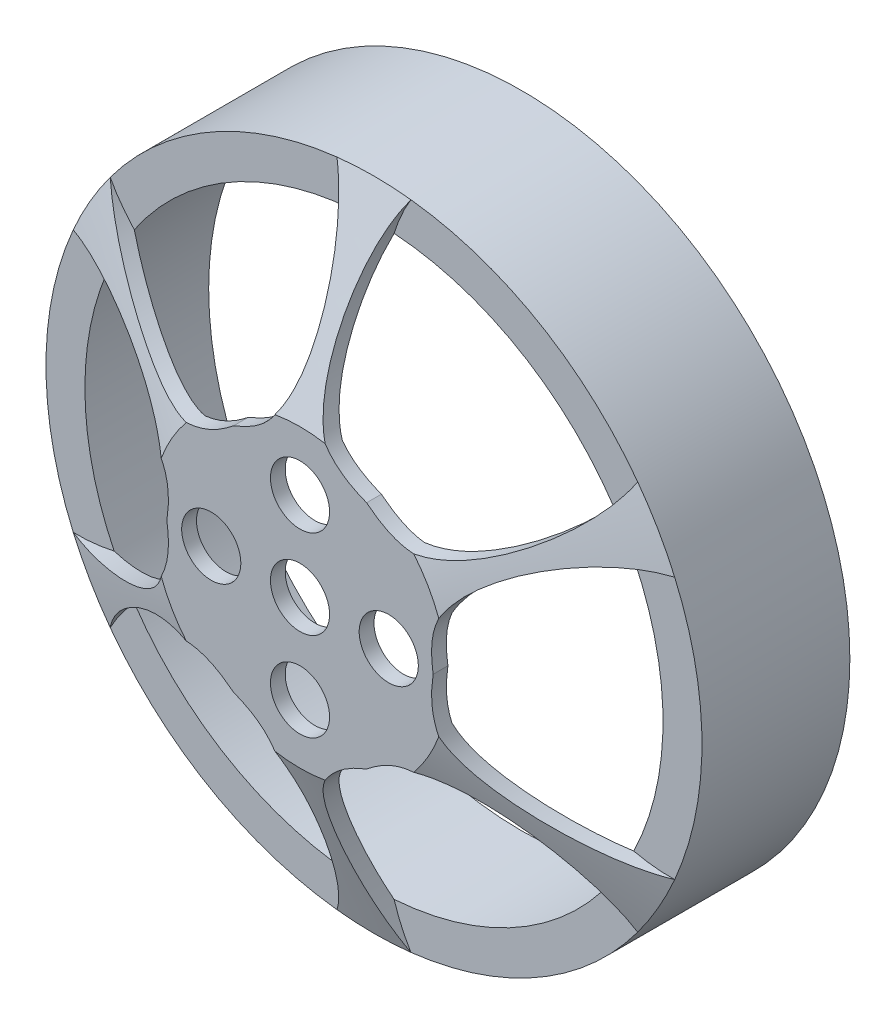
from build123d import *

# Parameters (mm, degrees)
SKETCH1_R           = 22.175
BOSS_EXTRUDE1_DEPTH = 10
SKETCH2_R           = 10
SHELL1_T            = -1
SKETCH3_R           = 2
CUT_EXTRUDE1_DEPTH  = 5


with BuildPart() as part:
    # Sketch1 → Boss-Extrude1 (new body)
    with BuildSketch(Plane.XY):
        Circle(SKETCH1_R)
    extrude(amount=BOSS_EXTRUDE1_DEPTH)

    # Sketch2 → section 0 of loft1
    with BuildSketch(Plane.XY.offset(15), mode=Mode.PRIVATE) as loft1_s0:
        Circle(SKETCH2_R)
    # loft up to a face of the part (loft1)
    loft([loft1_s0.sketch, Face(Wire([part.edges().sort_by_distance((-15.179832074, 16.164879313, 10))[0]]))])

    # Shell1
    shell1_openings = [part.faces().sort_by_distance(p)[0] for p in [
        (0, 0, 0),
    ]]
    offset(amount=SHELL1_T, openings=shell1_openings, kind=Kind.INTERSECTION)

    # Sketch3 → Cut-Extrude1 (cut)
    with BuildSketch(Plane.XY.offset(15)):
        Circle(SKETCH3_R)
        with Locations((0, 6)):
            Circle(SKETCH3_R)
        with Locations((6, 0)):
            Circle(SKETCH3_R)
        with Locations((0, -6)):
            Circle(SKETCH3_R)
        with Locations((-6, 0)):
            Circle(SKETCH3_R)
        with BuildLine():
            ThreePointArc((-20.331678877, 8.851748927), (-22.175, 0), (-20.331678877, -8.851748927))
            add(Edge.make_bspline(
                [(-20.331678877, -8.851748927), (-15.665918568, -9.044722303), (-9.625250911, -5.557141204), (-8.451567627, -3.688890956), (-9, 0)],
                knots=[0, 0, 0, 0, 0, 1, 1, 1, 1, 1], degree=4))
            add(Edge.make_bspline(
                [(-20.331678877, 8.851748927), (-15.665918568, 9.044722303), (-9.625250911, 5.557141204), (-8.451567627, 3.688890956), (-9, 0)],
                knots=[0, 0, 0, 0, 0, 1, 1, 1, 1, 1], degree=4))
        make_face()
        with BuildLine():
            ThreePointArc((-2.5, 22.033624872), (-11.0875, 19.204113329), (-17.831678877, 13.181875945))
            add(Edge.make_bspline(
                [(-17.831678877, 13.181875945), (-15.665918568, 9.044722303), (-9.625250911, 5.557141204), (-7.420457094, 5.474826789), (-4.5, 7.794228634)],
                knots=[0, 0, 0, 0, 0, 1, 1, 1, 1, 1], degree=4))
            add(Edge.make_bspline(
                [(-2.5, 22.033624872), (0, 18.089444605), (0, 11.114282409), (-1.031110534, 9.163717745), (-4.5, 7.794228634)],
                knots=[0, 0, 0, 0, 0, 1, 1, 1, 1, 1], degree=4))
        make_face()
        with BuildLine():
            ThreePointArc((17.831678877, 13.181875945), (11.0875, 19.204113329), (2.5, 22.033624872))
            add(Edge.make_bspline(
                [(2.5, 22.033624872), (0, 18.089444605), (0, 11.114282409), (1.031110534, 9.163717745), (4.5, 7.794228634)],
                knots=[0, 0, 0, 0, 0, 1, 1, 1, 1, 1], degree=4))
            add(Edge.make_bspline(
                [(17.831678877, 13.181875945), (15.665918568, 9.044722303), (9.625250911, 5.557141204), (7.420457094, 5.474826789), (4.5, 7.794228634)],
                knots=[0, 0, 0, 0, 0, 1, 1, 1, 1, 1], degree=4))
        make_face()
        with BuildLine():
            ThreePointArc((20.331678877, -8.851748927), (22.175, 0), (20.331678877, 8.851748927))
            add(Edge.make_bspline(
                [(20.331678877, 8.851748927), (15.665918568, 9.044722303), (9.625250911, 5.557141204), (8.451567627, 3.688890956), (9, 0)],
                knots=[0, 0, 0, 0, 0, 1, 1, 1, 1, 1], degree=4))
            add(Edge.make_bspline(
                [(20.331678877, -8.851748927), (15.665918568, -9.044722303), (9.625250911, -5.557141204), (8.451567627, -3.688890956), (9, 0)],
                knots=[0, 0, 0, 0, 0, 1, 1, 1, 1, 1], degree=4))
        make_face()
        with BuildLine():
            ThreePointArc((-17.831678877, -13.181875945), (-11.0875, -19.204113329), (-2.5, -22.033624872))
            add(Edge.make_bspline(
                [(-2.5, -22.033624872), (0, -18.089444605), (0, -11.114282409), (-1.031110534, -9.163717745), (-4.5, -7.794228634)],
                knots=[0, 0, 0, 0, 0, 1, 1, 1, 1, 1], degree=4))
            add(Edge.make_bspline(
                [(-17.831678877, -13.181875945), (-15.665918568, -9.044722303), (-9.625250911, -5.557141204), (-7.420457094, -5.474826789), (-4.5, -7.794228634)],
                knots=[0, 0, 0, 0, 0, 1, 1, 1, 1, 1], degree=4))
        make_face()
        with BuildLine():
            ThreePointArc((2.5, -22.033624872), (11.0875, -19.204113329), (17.831678877, -13.181875945))
            add(Edge.make_bspline(
                [(17.831678877, -13.181875945), (15.665918568, -9.044722303), (9.625250911, -5.557141204), (7.420457094, -5.474826789), (4.5, -7.794228634)],
                knots=[0, 0, 0, 0, 0, 1, 1, 1, 1, 1], degree=4))
            add(Edge.make_bspline(
                [(2.5, -22.033624872), (0, -18.089444605), (0, -11.114282409), (1.031110534, -9.163717745), (4.5, -7.794228634)],
                knots=[0, 0, 0, 0, 0, 1, 1, 1, 1, 1], degree=4))
        make_face()
    extrude(amount=-CUT_EXTRUDE1_DEPTH, mode=Mode.SUBTRACT)


solid = part.part
